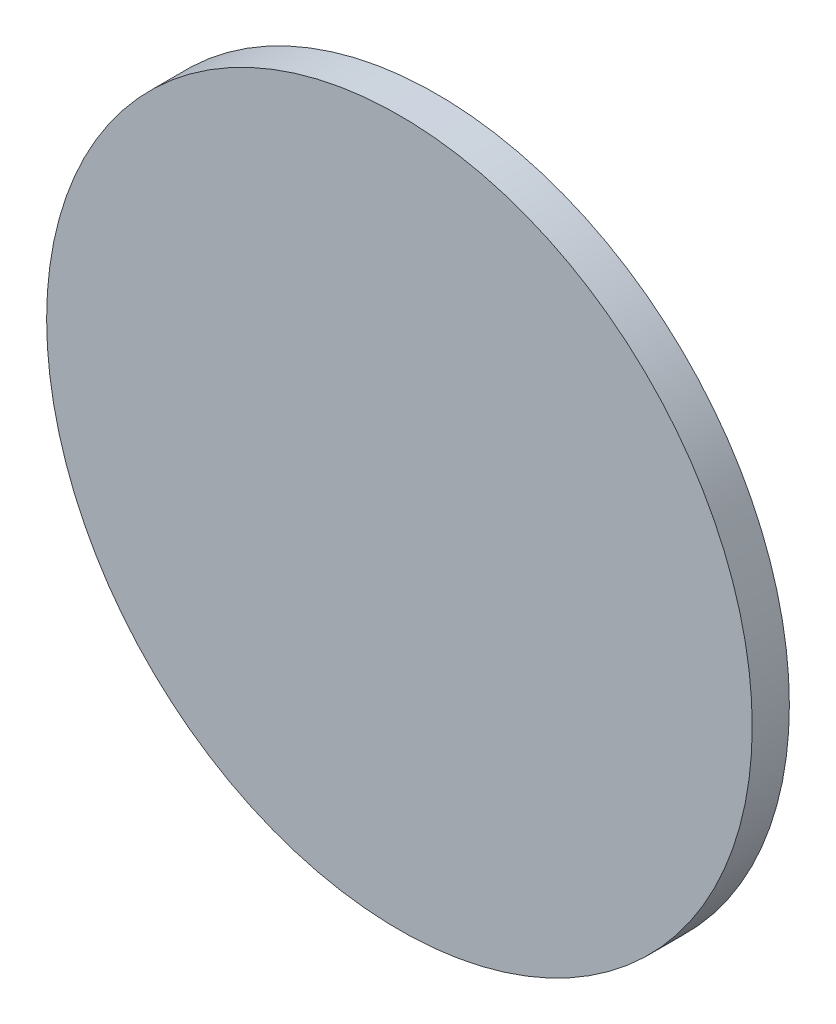
from build123d import *

# Parameters (mm, degrees)
SKETCH_1_R      = 19
EXTRUDE_1_DEPTH = 2


with BuildPart() as part:
    # Эскиз1 → Бобышка-Вытянуть1 (new body)
    with BuildSketch(Plane.XY):
        Circle(SKETCH_1_R)
    extrude(amount=EXTRUDE_1_DEPTH)


solid = part.part
